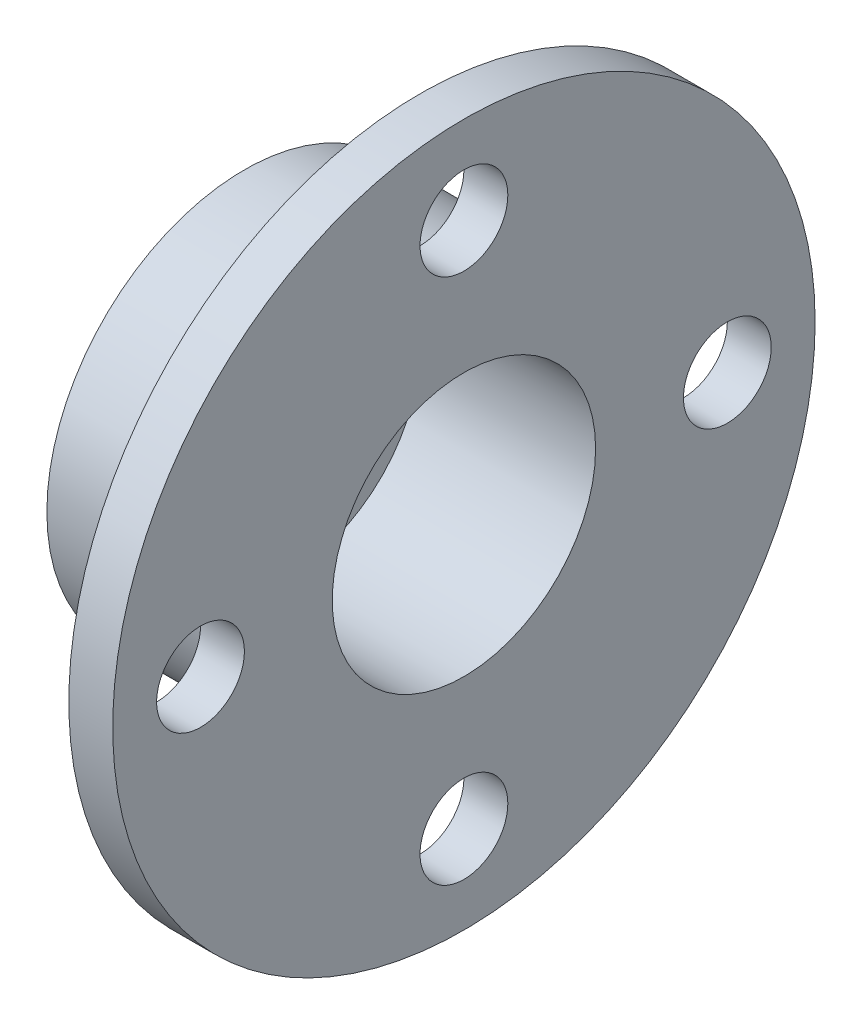
from build123d import *

# Parameters (mm, degrees)
SKETCH2_R          = 25.4
CUT_EXTRUDE1_DEPTH = 128


with BuildPart() as part:
    # Sketch1 → Revolve1 (revolve)
    with BuildSketch(Plane.XY):
        Polygon((-151.127552987, 114.3), (-49.527552987, 114.3), (-49.527552987, 203.2), (-24.127552987, 203.2), (-24.127552987, 76.2), (-125.727552987, 76.2), (-125.727552987, 50.8), (-151.127552987, 50.8), align=None)
    revolve(axis=Axis((0, 0, 0), (-1, 0, 0)))

    # Sketch2 → Cut-Extrude1 (cut, through all)
    with BuildSketch(Plane(origin=(-24.127552987, 0, 0), x_dir=(0, 0, -1), z_dir=(1, 0, 0))):
        with Locations((0, 152.4)):
            Circle(SKETCH2_R)
        with Locations((-152.4, 0)):
            Circle(SKETCH2_R)
        with Locations((152.4, 0)):
            Circle(SKETCH2_R)
        with Locations((0, -152.4)):
            Circle(SKETCH2_R)
    extrude(amount=-CUT_EXTRUDE1_DEPTH, mode=Mode.SUBTRACT)


solid = part.part
